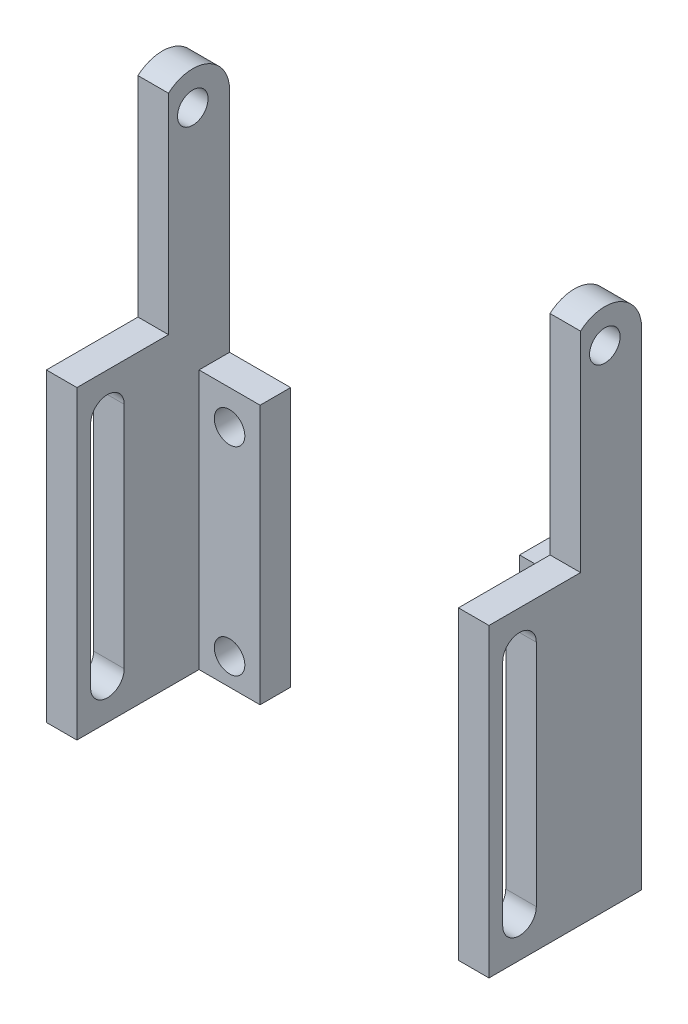
from build123d import *

# Parameters (mm, degrees)
SKETCH_1_W          = 2
SKETCH_1_H          = 35
EXTRUDE_1_DEPTH     = 4
EXTRUDE_1_2_DEPTH   = 4
SKETCH_2_W          = 4
SKETCH_2_H          = 17
EXTRUDE_2_DEPTH     = 2
SKETCH_3_R          = 1
CUT_EXTRUDE_1_DEPTH = 2
SKETCH_5_W          = 2
SKETCH_5_H          = 20
EXTRUDE_3_DEPTH     = 6
CUT_EXTRUDE_2_DEPTH = 29.99338081
CUT_EXTRUDE_3_DEPTH = 29.99338081
SKETCH_8_R          = 1
CUT_EXTRUDE_4_DEPTH = 29.99338081


with BuildPart() as part:
    # 草图1 → 凸台-拉伸1 (new body)
    with BuildSketch(Plane.XY):
        with Locations((-37.996690405, -20.5)):
            Rectangle(SKETCH_1_W, SKETCH_1_H)
    extrude(amount=-EXTRUDE_1_DEPTH)



with BuildPart() as body_2:
    # 草图1 → Extrude 1 2 (new body)
    with BuildSketch(Plane.XY):
        with Locations((-11.003309595, -20.5)):
            Rectangle(SKETCH_1_W, SKETCH_1_H)
    extrude(amount=-EXTRUDE_1_2_DEPTH)


with BuildPart() as part_1:
    add(part.part)

    add(body_2.part)  # 凸台-拉伸2 merges body 2
    # 草图2 → 凸台-拉伸2 (add)
    with BuildSketch(Plane(origin=(0, 0, -4), x_dir=(-1, 0, 0), z_dir=(0, 0, -1))):
        with Locations((34.996690405, -29.5)):
            Rectangle(SKETCH_2_W, SKETCH_2_H)
        with Locations((14.003309595, -29.5)):
            Rectangle(SKETCH_2_W, SKETCH_2_H)
    extrude(amount=-EXTRUDE_2_DEPTH)

    # 草图3 → 切除-拉伸1 (cut)
    with BuildSketch(Plane(origin=(0, 0, -4), x_dir=(-1, 0, 0), z_dir=(0, 0, -1))):
        with Locations((34.996690405, -36.24616654)):
            Circle(SKETCH_3_R)
        with Locations((34.996690405, -23.24616654)):
            Circle(SKETCH_3_R)
        with Locations((14.003309595, -36.24616654)):
            Circle(SKETCH_3_R)
        with Locations((14.003309595, -23.24616654)):
            Circle(SKETCH_3_R)
    extrude(amount=-CUT_EXTRUDE_1_DEPTH, mode=Mode.SUBTRACT)

    # 草图5 → 凸台-拉伸3 (add)
    with BuildSketch(Plane.XY):
        with Locations((-11.003309595, -28)):
            Rectangle(SKETCH_5_W, SKETCH_5_H)
        with Locations((-37.996690405, -28)):
            Rectangle(SKETCH_5_W, SKETCH_5_H)
    extrude(amount=EXTRUDE_3_DEPTH)

    # 草图6 → 切除-拉伸2 (cut, through all)
    with BuildSketch(Plane(origin=(-10.003309595, 0, 0), x_dir=(0, 0, -1), z_dir=(1, 0, 0))):
        with BuildLine():
            Line((-5.1, -20.5), (-5.1, -35.5))
            ThreePointArc((-5.1, -35.5), (-4, -36.6), (-2.9, -35.5))
            Line((-2.9, -35.5), (-2.9, -20.5))
            ThreePointArc((-2.9, -20.5), (-4, -19.4), (-5.1, -20.5))
        make_face()
    extrude(amount=-CUT_EXTRUDE_2_DEPTH, mode=Mode.SUBTRACT)

    # 草图7 → 切除-拉伸3 (cut, through all)
    with BuildSketch(Plane(origin=(-10.003309595, 0, 0), x_dir=(0, 0, -1), z_dir=(1, 0, 0))):
        with BuildLine():
            Line((0, -3), (0, -4.301364092))
            ThreePointArc((0, -4.301364092), (2.583976205, -3.916756735), (4, -6.112145643))
            Line((4, -6.112145643), (4, -3))
            Line((4, -3), (0, -3))
        make_face()
    extrude(amount=-CUT_EXTRUDE_3_DEPTH, mode=Mode.SUBTRACT)

    # 草图8 → 切除-拉伸4 (cut, through all)
    with BuildSketch(Plane(origin=(-10.003309595, 0, 0), x_dir=(0, 0, -1), z_dir=(1, 0, 0))):
        with Locations((1.590133771, -5.912145643)):
            Circle(SKETCH_8_R)
    extrude(amount=-CUT_EXTRUDE_4_DEPTH, mode=Mode.SUBTRACT)


solid = part_1.part
